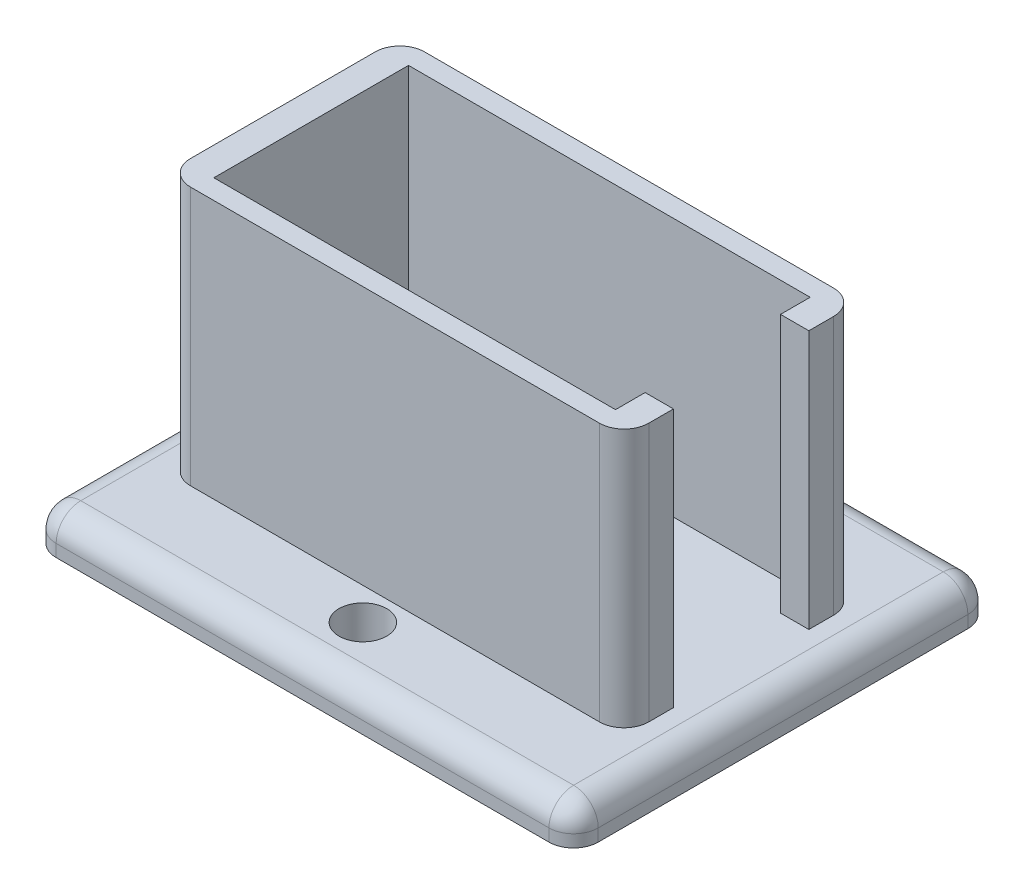
from build123d import *

# Parameters (mm, degrees)
SKETCH1_W           = 55.88
SKETCH1_H           = 43.18
BOSS_EXTRUDE1_DEPTH = 3.81
FILLET1_R           = 2.54
SKETCH3_W           = 47.244
SKETCH3_H           = 24.13
BOSS_EXTRUDE2_DEPTH = 26.67
FILLET2_R           = 2.54
SKETCH6_W           = 41.402
SKETCH6_H           = 20.066
CUT_EXTRUDE1_DEPTH  = 26.67
SKETCH7_R           = 2.461857572
CUT_EXTRUDE2_DEPTH  = 3.81
SKETCH9_W           = 3.778787448
SKETCH9_H           = 13.955771
CUT_EXTRUDE4_DEPTH  = 26.67


with BuildPart() as part:
    # Sketch1 → Boss-Extrude1 (new body)
    with BuildSketch(Plane(origin=(0, 0, 0), x_dir=(1, 0, 0), z_dir=(0, 1, 0))):
        Rectangle(SKETCH1_W, SKETCH1_H)
    extrude(amount=BOSS_EXTRUDE1_DEPTH)

    # Fillet1
    fillet1_edges = [part.edges().sort_by_distance(p)[0] for p in [
        (-27.94, 3.81, 0),
        (0, 3.81, 21.59),
        (27.94, 3.81, 0),
        (27.94, 1.905, 21.59),
        (-27.94, 1.905, 21.59),
        (-27.94, 1.905, -21.59),
        (27.94, 1.905, -21.59),
        (0, 3.81, -21.59),
    ]]
    fillet(fillet1_edges, radius=FILLET1_R)

    # Sketch3 → Boss-Extrude2 (add)
    with BuildSketch(Plane(origin=(0, 3.81, 0), x_dir=(1, 0, 0), z_dir=(0, 1, 0))):
        Rectangle(SKETCH3_W, SKETCH3_H)
    extrude(amount=BOSS_EXTRUDE2_DEPTH)

    # Fillet2
    fillet2_edges = [part.edges().sort_by_distance(p)[0] for p in [
        (23.622, 17.145, 12.065),
        (23.622, 17.145, -12.065),
        (-23.622, 17.145, -12.065),
        (-23.622, 17.145, 12.065),
    ]]
    fillet(fillet2_edges, radius=FILLET2_R)

    # Sketch6 → Cut-Extrude1 (cut)
    with BuildSketch(Plane(origin=(0, 30.48, 0), x_dir=(1, 0, 0), z_dir=(0, 1, 0))):
        Rectangle(SKETCH6_W, SKETCH6_H)
    extrude(amount=-CUT_EXTRUDE1_DEPTH, mode=Mode.SUBTRACT)

    # Sketch7 → Cut-Extrude2 (cut)
    with BuildSketch(Plane(origin=(0, 3.81, 0), x_dir=(1, 0, 0), z_dir=(0, 1, 0))):
        with Locations((0, 15.373463193)):
            Circle(SKETCH7_R)
        with Locations((0, -15.373463193)):
            Circle(SKETCH7_R)
    extrude(amount=-CUT_EXTRUDE2_DEPTH, mode=Mode.SUBTRACT)

    # Sketch9 → Cut-Extrude4 (cut)
    with BuildSketch(Plane(origin=(0, 30.48, 0), x_dir=(1, 0, 0), z_dir=(0, 1, 0))):
        with Locations((21.732606276, 0)):
            Rectangle(SKETCH9_W, SKETCH9_H)
    extrude(amount=-CUT_EXTRUDE4_DEPTH, mode=Mode.SUBTRACT)


solid = part.part
